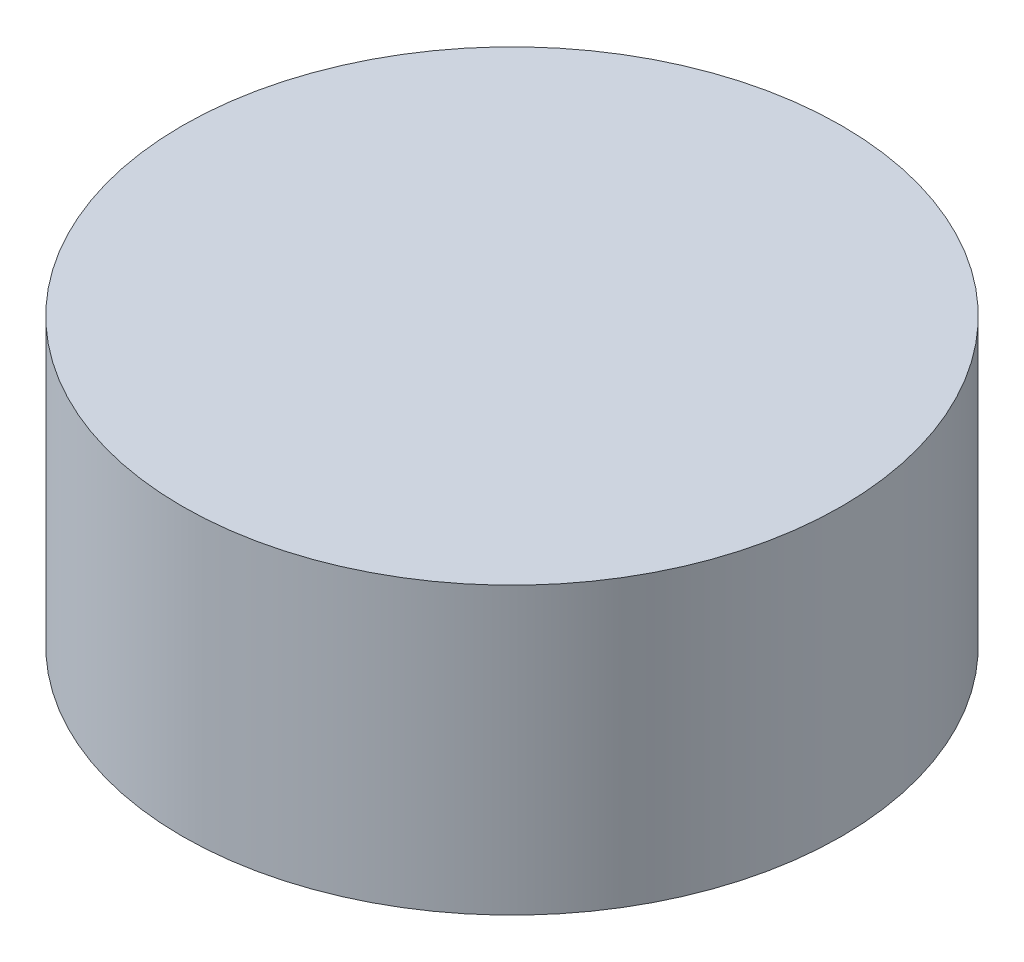
from build123d import *

# Parameters (mm, degrees)
SKETCH1_R           = 9
BOSS_EXTRUDE1_DEPTH = 7.8


with BuildPart() as part:
    # Sketch1 → Boss-Extrude1 (new body)
    with BuildSketch(Plane(origin=(0, 0, 0), x_dir=(1, 0, 0), z_dir=(0, 1, 0))):
        Circle(SKETCH1_R)
    extrude(amount=BOSS_EXTRUDE1_DEPTH)


solid = part.part
